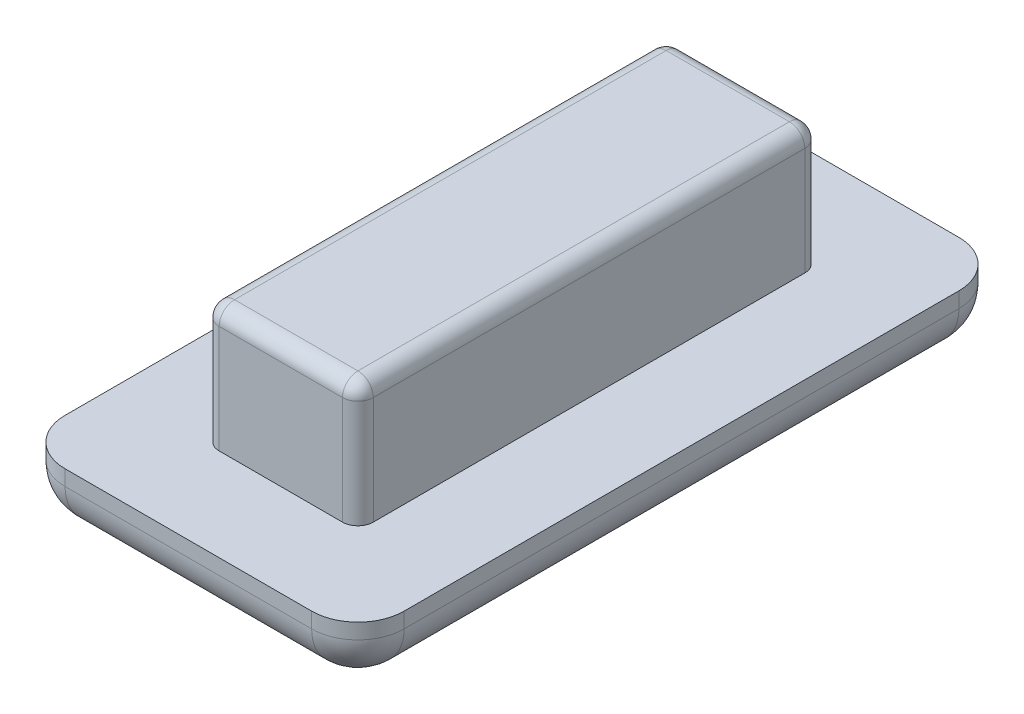
from build123d import *

# Parameters (mm, degrees)
SKETCH1_W           = 5
SKETCH1_H           = 15
BOSS_EXTRUDE1_DEPTH = 4
SKETCH2_W           = 11
SKETCH2_H           = 21
BOSS_EXTRUDE2_DEPTH = 2
FILLET1_R           = 0.5
FILLET2_R           = 1.5


with BuildPart() as part:
    # Sketch1 → Boss-Extrude1 (new body)
    with BuildSketch(Plane(origin=(0, 0, 0), x_dir=(1, 0, 0), z_dir=(0, 1, 0))):
        with Locations((3, 8)):
            Rectangle(SKETCH1_W, SKETCH1_H)
    extrude(amount=BOSS_EXTRUDE1_DEPTH)

    # Sketch2 → Boss-Extrude2 (add)
    with BuildSketch(Plane.XZ):
        with Locations((3, -8)):
            Rectangle(SKETCH2_W, SKETCH2_H)
    extrude(amount=BOSS_EXTRUDE2_DEPTH)

    # Fillet1
    fillet1_edges = [part.edges().sort_by_distance(p)[0] for p in [
        (5.5, 4, -8),
        (3, 4, -15.5),
        (0.5, 4, -8),
        (0.5, 2, -15.5),
        (5.5, 2, -15.5),
        (5.5, 2, -0.5),
        (0.5, 2, -0.5),
        (3, 4, -0.5),
    ]]
    fillet(fillet1_edges, radius=FILLET1_R)

    # Fillet2
    fillet2_edges = [part.edges().sort_by_distance(p)[0] for p in [
        (8.5, -1, -18.5),
        (8.5, -1, 2.5),
        (-2.5, -1, 2.5),
        (-2.5, -1, -18.5),
        (8.5, -2, -8),
        (3, -2, 2.5),
        (-2.5, -2, -8),
        (3, -2, -18.5),
    ]]
    fillet(fillet2_edges, radius=FILLET2_R)


solid = part.part
